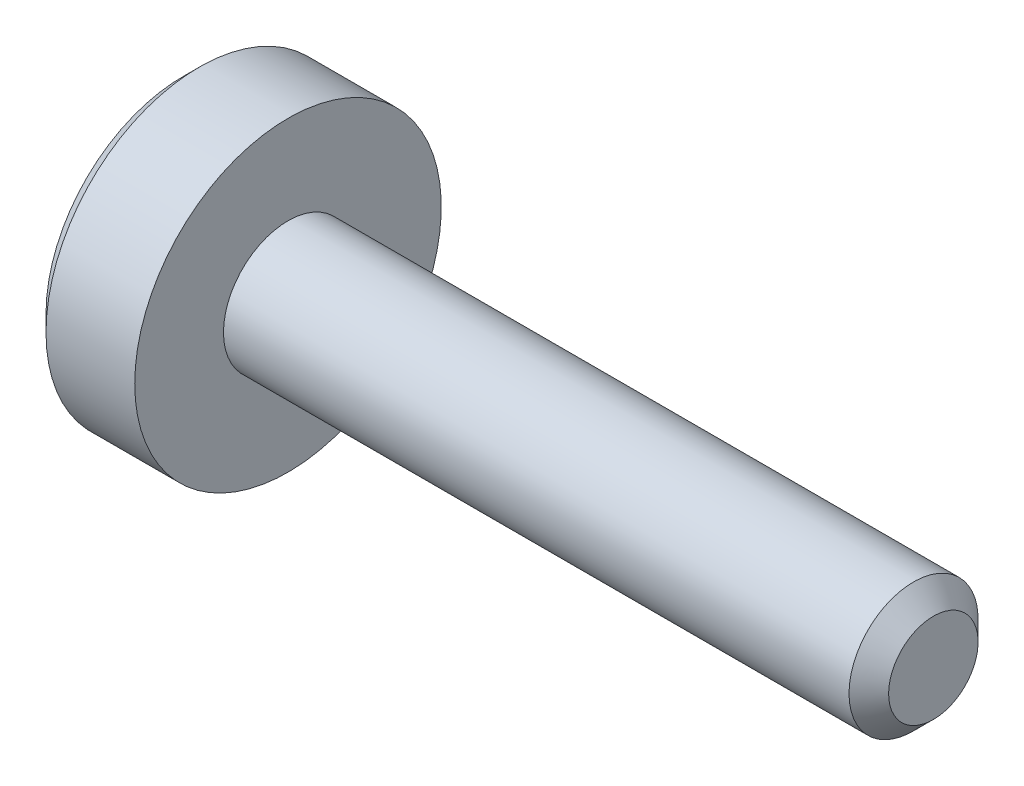
from build123d import *

# Parameters (mm, degrees)
CUT_EXTRUDE1_DEPTH = 0.7


with BuildPart() as part:
    # Sketch1 → Revolve1 (revolve)
    with BuildSketch(Plane.XY):
        Polygon((-1.3, 0), (-1.3, 1.7), (-1.1, 1.9), (0, 1.9), (0, 0.8), (7.7545, 0.8), (8, 0.5545), (8, 0), align=None)
    revolve(axis=Axis((8, 0, 0), (-1, 0, 0)))

    # Sketch2 → Cut-Extrude1 (cut)
    with BuildSketch(Plane(origin=(-1.3, 0, 0), x_dir=(0, 0, -1), z_dir=(1, 0, 0))):
        Polygon((-0.65, -0.375277675), (0, -0.75055535), (0.65, -0.375277675), (0.65, 0.375277675), (0, 0.75055535), (-0.65, 0.375277675), align=None)
    extrude(amount=CUT_EXTRUDE1_DEPTH, mode=Mode.SUBTRACT)


solid = part.part
